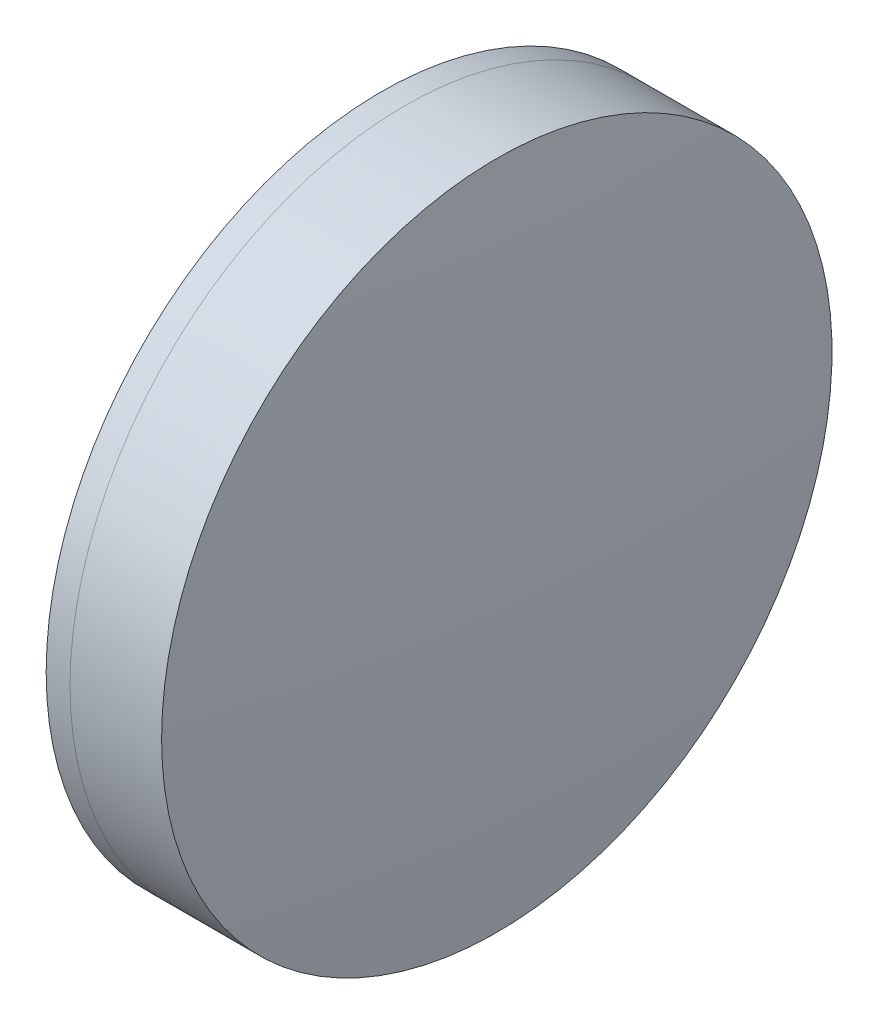
from build123d import *


with BuildPart() as part:
    # 草图1 one side → 旋转1 (revolve)
    with BuildSketch(Plane(origin=(0, 0, 0), x_dir=(1, 0, 0), z_dir=(0, 1, 0)), mode=Mode.PRIVATE) as revolve_1_sk:
        with BuildLine():
            ThreePointArc((534.258518881, 25.4), (530.446055605, 12.953482545), (529.158436509, 0))
            Line((529.158436509, 0), (542.158436509, 0))
            ThreePointArc((542.158436509, 0), (540.614224506, 13.060136051), (536.066752449, 25.4))
            Line((536.066752449, 25.4), (534.258518881, 25.4))
        make_face()
    revolve(revolve_1_sk.sketch.rotate(Axis((124.523309526, 0, 0), (1, 0, 0)), 180), axis=Axis((124.523309526, 0, 0), (1, 0, 0)))  # turned: the seam where the file's is


with BuildPart() as body_2:
    # 草图2 one side → 旋转3 (revolve)
    with BuildSketch(Plane(origin=(0, 0, 0), x_dir=(1, 0, 0), z_dir=(0, 1, 0)), mode=Mode.PRIVATE) as revolve_3_sk:
        with BuildLine():
            Line((543.006463877, 25.4), (536.066752449, 25.4))
            ThreePointArc((536.066752449, 25.4), (540.614224506, 13.060136051), (542.158436509, 0))
            Line((542.158436509, 0), (544.158436509, 0))
            ThreePointArc((544.158436509, 0), (543.870295409, 12.713054717), (543.006463877, 25.4))
        make_face()
    revolve(revolve_3_sk.sketch.rotate(Axis((-0.551919993, 0, 0), (1, 0, 0)), 180), axis=Axis((-0.551919993, 0, 0), (1, 0, 0)))  # turned: the seam where the file's is


solid = Compound([part.part, body_2.part])
